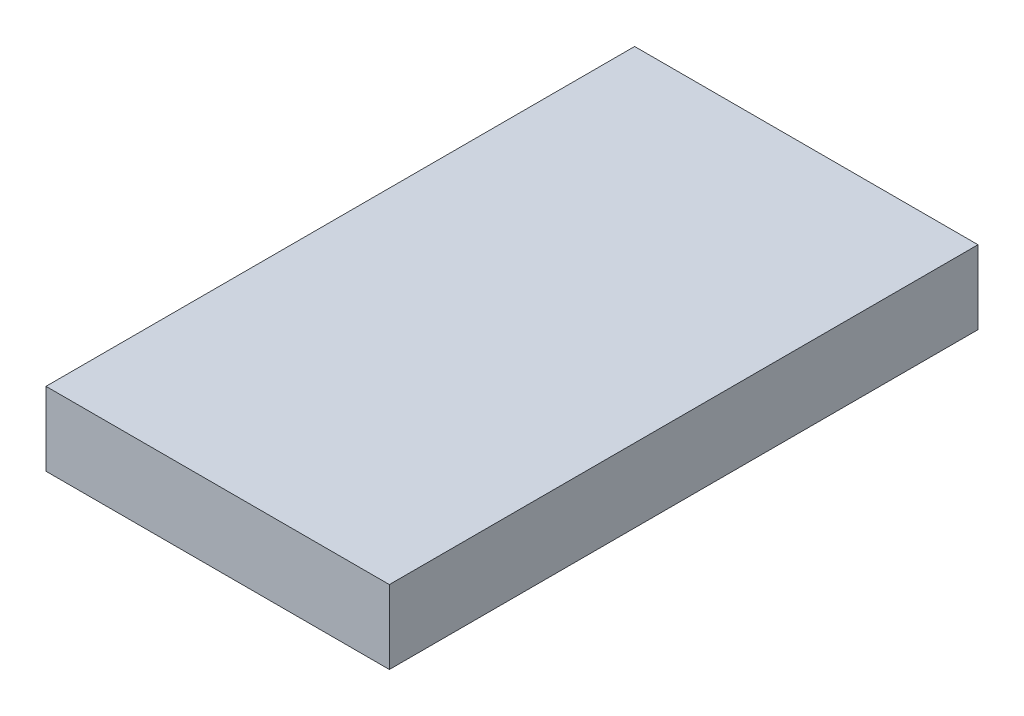
from build123d import *

# Parameters (mm, degrees)
SKETCH1_W           = 35.56
SKETCH1_H           = 60.96
BOSS_EXTRUDE1_DEPTH = 7.62


with BuildPart() as part:
    # Sketch1 → Boss-Extrude1 (new body)
    with BuildSketch(Plane(origin=(0, 0, 0), x_dir=(1, 0, 0), z_dir=(0, 1, 0))):
        with Locations((17.78, 30.48)):
            Rectangle(SKETCH1_W, SKETCH1_H)
    extrude(amount=BOSS_EXTRUDE1_DEPTH)


solid = part.part
